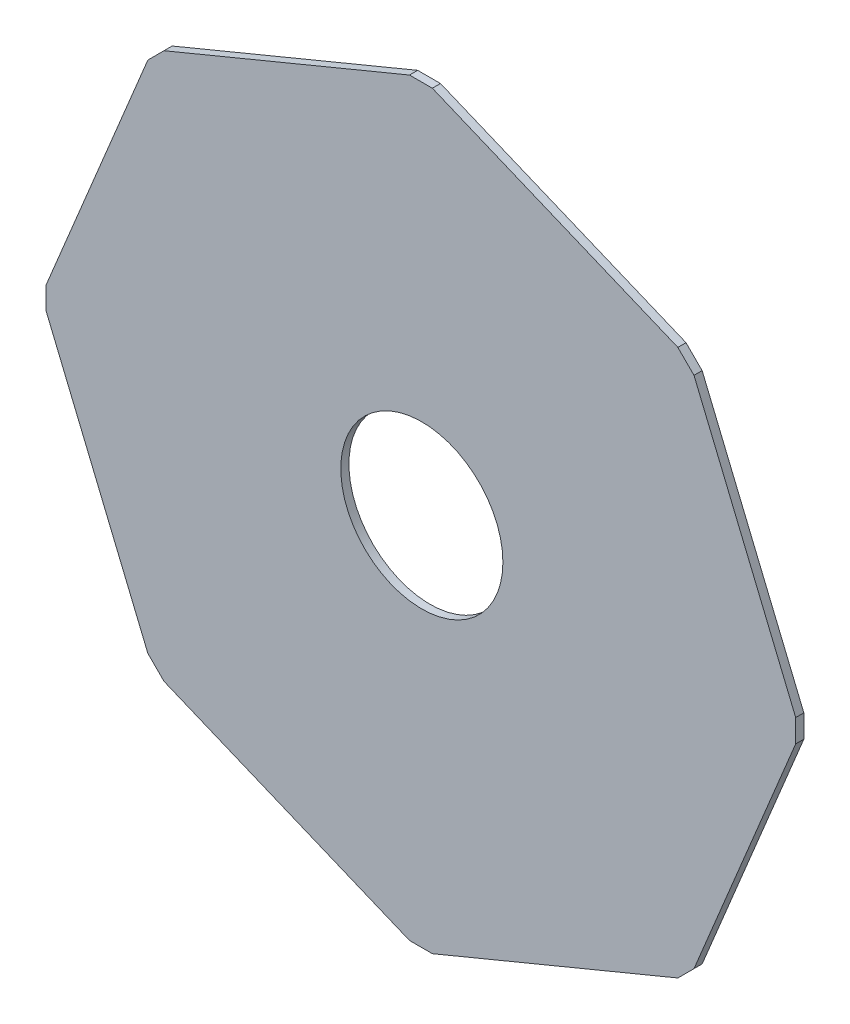
from build123d import *

# Parameters (mm, degrees)
SKETCH1_R           = 49.75
BOSS_EXTRUDE1_DEPTH = 5


with BuildPart() as part:
    # Sketch1 → Boss-Extrude1 (new body)
    with BuildSketch(Plane.XY):
        Polygon((-230.557942617, -6.721028691), (-168.142249758, -157.405840896), (-158.242754822, -167.305335833), (-7.557942617, -229.721028692), (6.442057383, -229.721028692), (157.126869588, -167.305335833), (167.026364524, -157.405840896), (229.442057383, -6.721028691), (229.442057383, 7.278971309), (167.026364524, 157.963783513), (157.126869588, 167.86327845), (6.442057383, 230.278971308), (-7.557942617, 230.278971308), (-158.242754822, 167.86327845), (-168.142249758, 157.963783513), (-230.557942617, 7.278971308), align=None)
        Circle(SKETCH1_R, mode=Mode.SUBTRACT)
    extrude(amount=BOSS_EXTRUDE1_DEPTH)


solid = part.part
